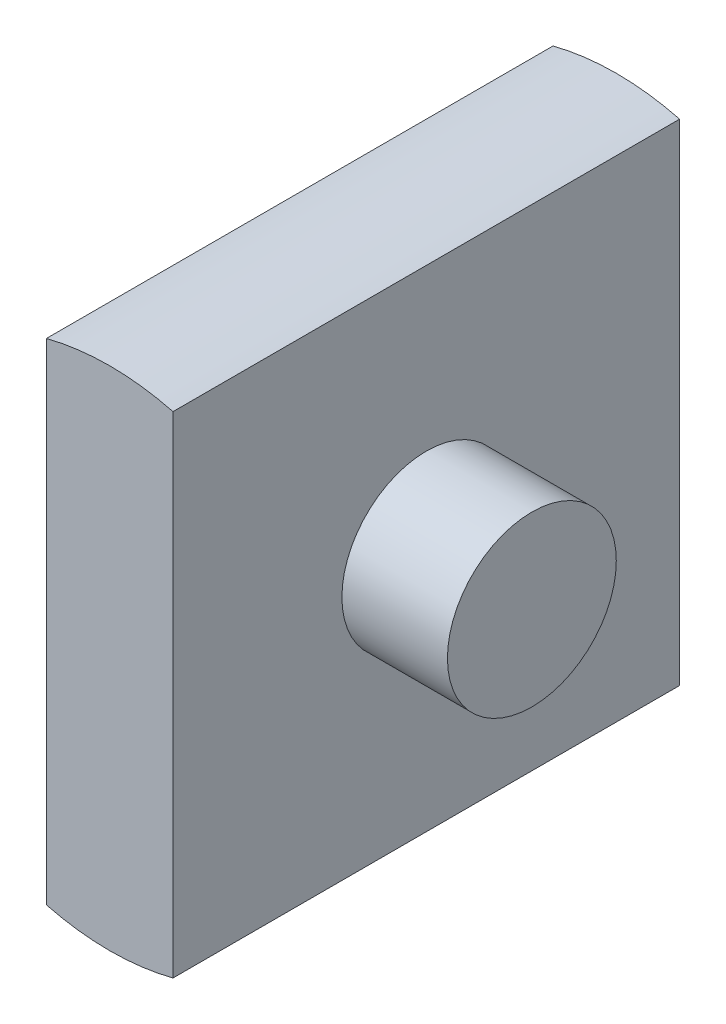
from build123d import *

# Parameters (mm, degrees)
BOSS_EXTRUDE1_DEPTH = 60
SKETCH2_TOOL_BASE_R = 10
BOSS_EXTRUDE2_DEPTH = 20


with BuildPart() as part:
    # sketch1_tool_base → Boss-Extrude1 (new body)
    with BuildSketch(Plane.XY):
        with BuildLine():
            Line((-7.5, 29.047375097), (-7.5, -29.047375097))
            ThreePointArc((-7.5, -29.047375097), (0, -30), (7.5, -29.047375097))
            Line((7.5, -29.047375097), (7.5, 29.047375097))
            ThreePointArc((7.5, 29.047375097), (0, 30), (-7.5, 29.047375097))
        make_face()
    extrude(amount=BOSS_EXTRUDE1_DEPTH)

    # sketch2_tool_base → Boss-Extrude2 (add, symmetric)
    with BuildSketch(Plane(origin=(0, 0, 0), x_dir=(0, 0, -1), z_dir=(1, 0, 0))):
        with Locations((-30, 0)):
            Circle(SKETCH2_TOOL_BASE_R)
    extrude(amount=BOSS_EXTRUDE2_DEPTH, both=True)


solid = part.part
